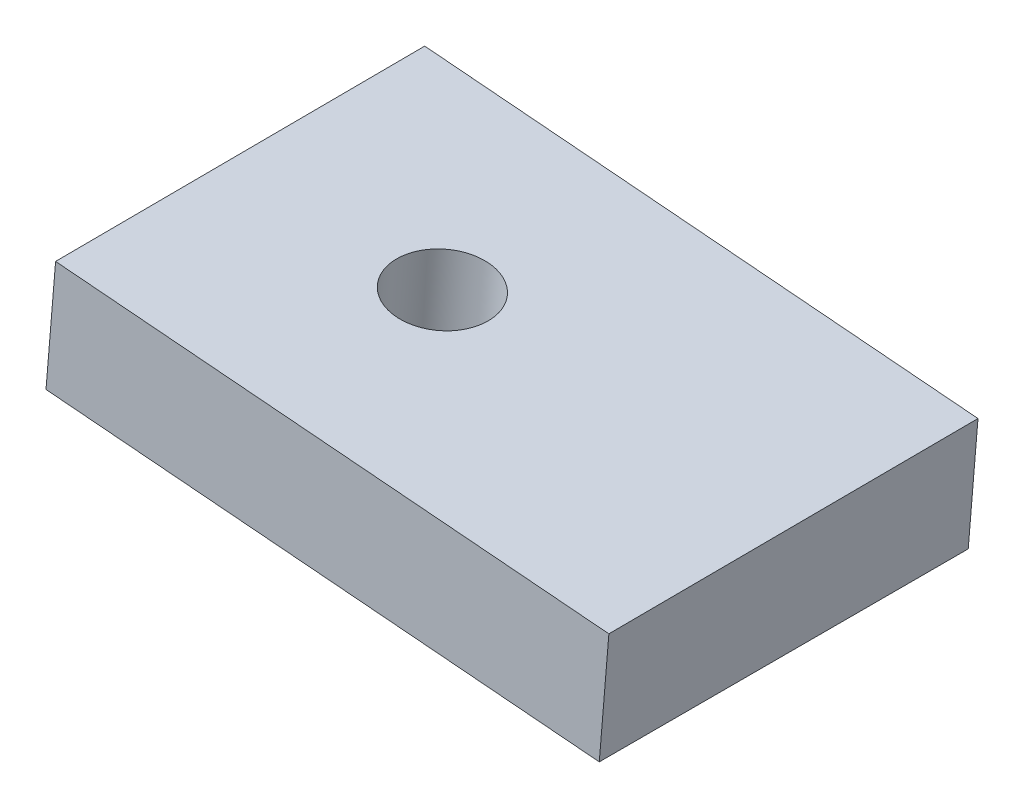
from build123d import *

# Parameters (mm, degrees)
SKETCH1_W                 = 15.047570974
SKETCH1_H                 = 10
BOSS_EXTRUDE1_DEPTH       = 3.203817716
DRAFT1_ANGLE              = -0.325763712
F_2_CLEARANCE_HOLE1_D     = 2.5
F_2_CLEARANCE_HOLE1_DEPTH = 4.421800182


with BuildPart() as part:
    # Sketch1 → Boss-Extrude1 (new body)
    with BuildSketch(Plane(origin=(-1.315367261, -15.86205167, 0), x_dir=(0.99657932, -0.082641756, 0), z_dir=(-0.082641756, -0.99657932, 0))):
        with Locations((-16.701480395, 5)):
            Rectangle(SKETCH1_W, SKETCH1_H)
    extrude(amount=-BOSS_EXTRUDE1_DEPTH)

    # Draft1
    draft1_faces = [part.faces().sort_by_distance(p)[0] for p in [
        (-17.694948105, -11.288953517, 5),
    ]]
    draft(draft1_faces, Plane(origin=(-25.192997126, -10.66717467, 0), x_dir=(-1, 0, 0), z_dir=(0, 0, -1)), DRAFT1_ANGLE)

    # #2 Clearance Hole1
    with Locations(Plane(origin=(-1.052360177, -12.690441673, 0), x_dir=(0.99657932, -0.082641756, 0), z_dir=(0.082641756, 0.99657932, 0))):
        with Locations((-18.725265882, -5)):
            Hole(F_2_CLEARANCE_HOLE1_D / 2, depth=F_2_CLEARANCE_HOLE1_DEPTH)


solid = part.part
